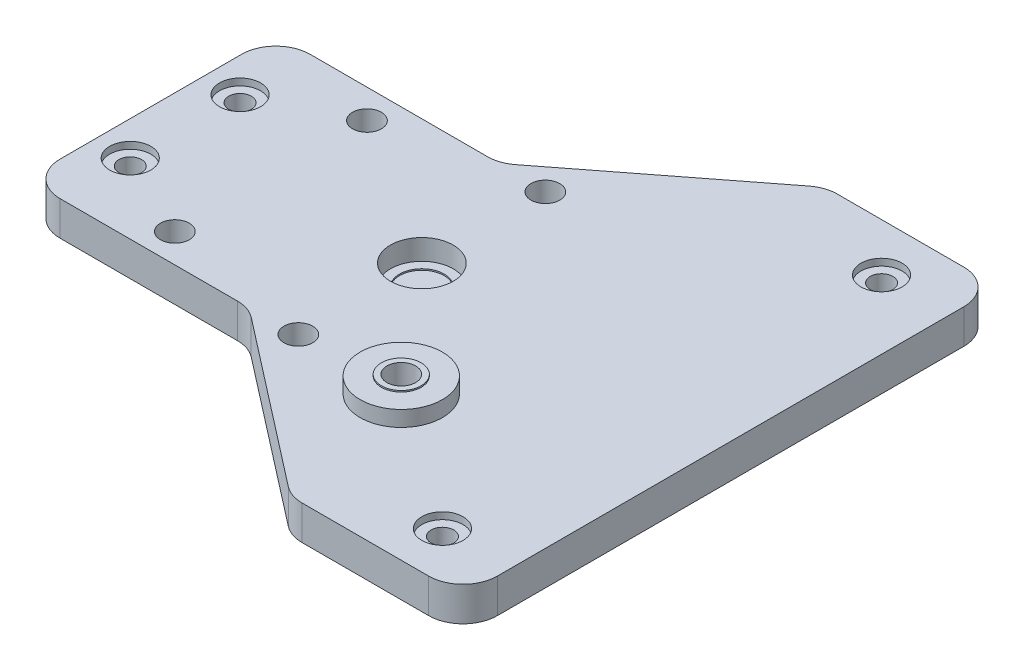
from build123d import *

# Parameters (mm, degrees)
SKETCH1_W           = 115
SKETCH1_H           = 60
SKETCH1_R           = 2.1
BOSS_EXTRUDE1_DEPTH = 5
SKETCH2_R           = 4.575
CUT_EXTRUDE1_DEPTH  = 3
SKETCH3_R           = 3.25
CUT_EXTRUDE2_DEPTH  = 0.2
SKETCH4_R           = 1.65
CUT_EXTRUDE3_DEPTH  = 6
CUT_EXTRUDE4_DEPTH  = 6
BOSS_EXTRUDE2_DEPTH = 5
SKETCH8_R           = 1.65
CUT_EXTRUDE5_DEPTH  = 6
FILLET1_R           = 5
SKETCH9_R           = 6
SKETCH9_R_2         = 2.1
BOSS_EXTRUDE3_DEPTH = 2.275
SKETCH10_R          = 2.9
SKETCH10_R_2        = 2.1
BOSS_EXTRUDE4_DEPTH = 0.2
SKETCH11_R          = 3
CUT_EXTRUDE6_DEPTH  = 1


with BuildPart() as part:
    # Sketch1 → Boss-Extrude1 (new body)
    with BuildSketch(Plane(origin=(0, 0, 0), x_dir=(1, 0, 0), z_dir=(0, 1, 0))):
        with Locations((-12.5, 0)):
            Rectangle(SKETCH1_W, SKETCH1_H)
        with Locations((-22, 14)):
            Circle(SKETCH1_R, mode=Mode.SUBTRACT)
        with Locations((0, 18)):
            Circle(SKETCH1_R, mode=Mode.SUBTRACT)
        with Locations((0, -18)):
            Circle(SKETCH1_R, mode=Mode.SUBTRACT)
        with Locations((-22, -14)):
            Circle(SKETCH1_R, mode=Mode.SUBTRACT)
        with Locations((15, -18)):
            Circle(SKETCH1_R, mode=Mode.SUBTRACT)
    extrude(amount=BOSS_EXTRUDE1_DEPTH)

    # Sketch2 → Cut-Extrude1 (cut)
    with BuildSketch(Plane(origin=(0, 5, 0), x_dir=(1, 0, 0), z_dir=(0, 1, 0))):
        Circle(SKETCH2_R)
    extrude(amount=-CUT_EXTRUDE1_DEPTH, mode=Mode.SUBTRACT)

    # Sketch3 → Cut-Extrude2 (cut)
    with BuildSketch(Plane(origin=(0, 2, 0), x_dir=(1, 0, 0), z_dir=(0, 1, 0))):
        Circle(SKETCH3_R)
    extrude(amount=-CUT_EXTRUDE2_DEPTH, mode=Mode.SUBTRACT)

    # Sketch4 → Cut-Extrude3 (cut, through all)
    with BuildSketch(Plane(origin=(0, 5, 0), x_dir=(1, 0, 0), z_dir=(0, 1, 0))):
        with Locations((-34.5, -8)):
            Circle(SKETCH4_R)
        with Locations((-34.5, 8)):
            Circle(SKETCH4_R)
    extrude(amount=-CUT_EXTRUDE3_DEPTH, mode=Mode.SUBTRACT)

    # Sketch6 → Cut-Extrude4 (cut, through all)
    with BuildSketch(Plane(origin=(0, 5, 0), x_dir=(1, 0, 0), z_dir=(0, 1, 0))):
        with BuildLine():
            Line((-22, 18.221576202), (-34.5, 18.221576202))
            ThreePointArc((-34.5, 18.221576202), (-38.035533906, 16.757110108), (-39.5, 13.221576202))
            Line((-39.5, 13.221576202), (-39.5, -13.221576202))
            ThreePointArc((-39.5, -13.221576202), (-38.035533906, -16.757110108), (-34.5, -18.221576202))
            Line((-34.5, -18.221576202), (-22, -18.221576202))
            Line((-22, -18.221576202), (-8.297519941, -18.221576202))
            Line((-8.297519941, -18.221576202), (-6.951019319, -18.221576202))
            Line((-6.951019319, -18.221576202), (19.301199277, -38.580439602))
            Line((19.301199277, -38.580439602), (-22, -30))
            Line((-22, -30), (-70, -30))
            Line((-70, -30), (-70, 30))
            Line((-70, 30), (-22, 30))
            Line((-22, 30), (19.301199277, 38.580439602))
            Line((19.301199277, 38.580439602), (-6.951019319, 18.221576202))
            Line((-6.951019319, 18.221576202), (-8.297519941, 18.221576202))
            Line((-8.297519941, 18.221576202), (-22, 18.221576202))
        make_face()
    extrude(amount=-CUT_EXTRUDE4_DEPTH, mode=Mode.SUBTRACT)

    # Sketch7 → Boss-Extrude2 (add)
    with BuildSketch(Plane(origin=(0, 5, 0), x_dir=(1, 0, 0), z_dir=(0, 1, 0))):
        Polygon((19.842211368, 39), (8.23694821, 30), (45, 30), (45, 39), align=None)
        Polygon((45, -30), (8.23694821, -30), (19.842211368, -39), (45, -39), align=None)
    extrude(amount=-BOSS_EXTRUDE2_DEPTH)

    # Sketch8 → Cut-Extrude5 (cut, through all)
    with BuildSketch(Plane(origin=(0, 5, 0), x_dir=(1, 0, 0), z_dir=(0, 1, 0))):
        with Locations((35, 32)):
            Circle(SKETCH8_R)
        with Locations((35, -32)):
            Circle(SKETCH8_R)
    extrude(amount=-CUT_EXTRUDE5_DEPTH, mode=Mode.SUBTRACT)

    # Fillet1
    fillet1_edges = [part.edges().sort_by_distance(p)[0] for p in [
        (45, 2.5, -39),
        (19.842211368, 2.5, -39),
        (19.842211368, 2.5, 39),
        (45, 2.5, 39),
        (-6.951019319, 2.5, 18.221576202),
        (-6.951019319, 2.5, -18.221576202),
    ]]
    fillet(fillet1_edges, radius=FILLET1_R)

    # Sketch9 → Boss-Extrude3 (add)
    with BuildSketch(Plane(origin=(0, 5, 0), x_dir=(1, 0, 0), z_dir=(0, 1, 0))):
        with Locations((15, -18)):
            Circle(SKETCH9_R)
        with Locations((15, -18)):
            Circle(SKETCH9_R_2, mode=Mode.SUBTRACT)
    extrude(amount=BOSS_EXTRUDE3_DEPTH)

    # Sketch10 → Boss-Extrude4 (add)
    with BuildSketch(Plane(origin=(0, 7.275, 0), x_dir=(1, 0, 0), z_dir=(0, 1, 0))):
        with Locations((15, -18)):
            Circle(SKETCH10_R)
        with Locations((15, -18)):
            Circle(SKETCH10_R_2, mode=Mode.SUBTRACT)
    extrude(amount=BOSS_EXTRUDE4_DEPTH)

    # Sketch11 → Cut-Extrude6 (cut)
    with BuildSketch(Plane(origin=(0, 5, 0), x_dir=(1, 0, 0), z_dir=(0, 1, 0))):
        with Locations((-34.5, 8)):
            Circle(SKETCH11_R)
        with Locations((-34.5, -8)):
            Circle(SKETCH11_R)
        with Locations((35, -32)):
            Circle(SKETCH11_R)
        with Locations((35, 32)):
            Circle(SKETCH11_R)
    extrude(amount=-CUT_EXTRUDE6_DEPTH, mode=Mode.SUBTRACT)


solid = part.part
